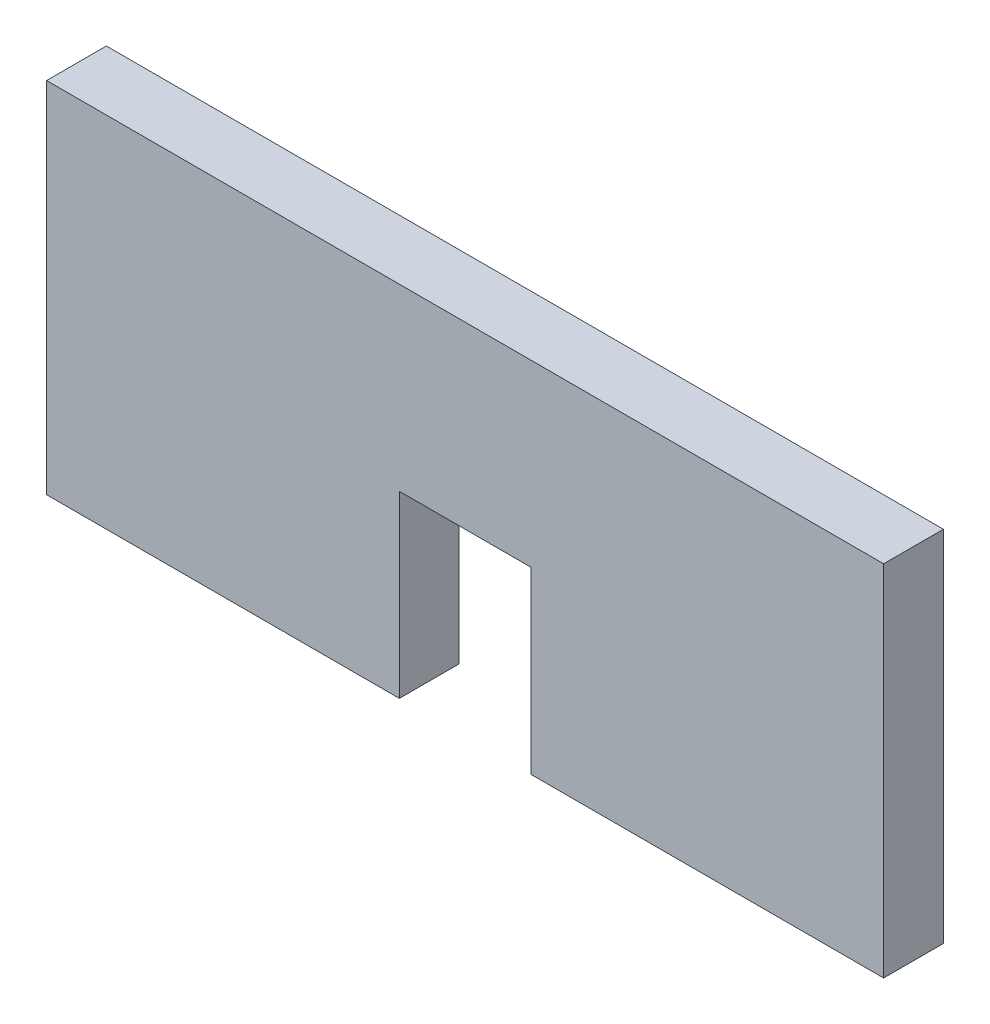
from build123d import *

# Parameters (mm, degrees)
BOSS_EXTRUDE1_DEPTH = 50


with BuildPart() as part:
    # Sketch1 → Boss-Extrude1 (new body)
    with BuildSketch(Plane.XY):
        Polygon((-295, 0), (0, 0), (0, 300), (-700, 300), (-700, 0), (-405, 0), (-405, 150), (-295, 150), align=None)
    extrude(amount=BOSS_EXTRUDE1_DEPTH)


solid = part.part
